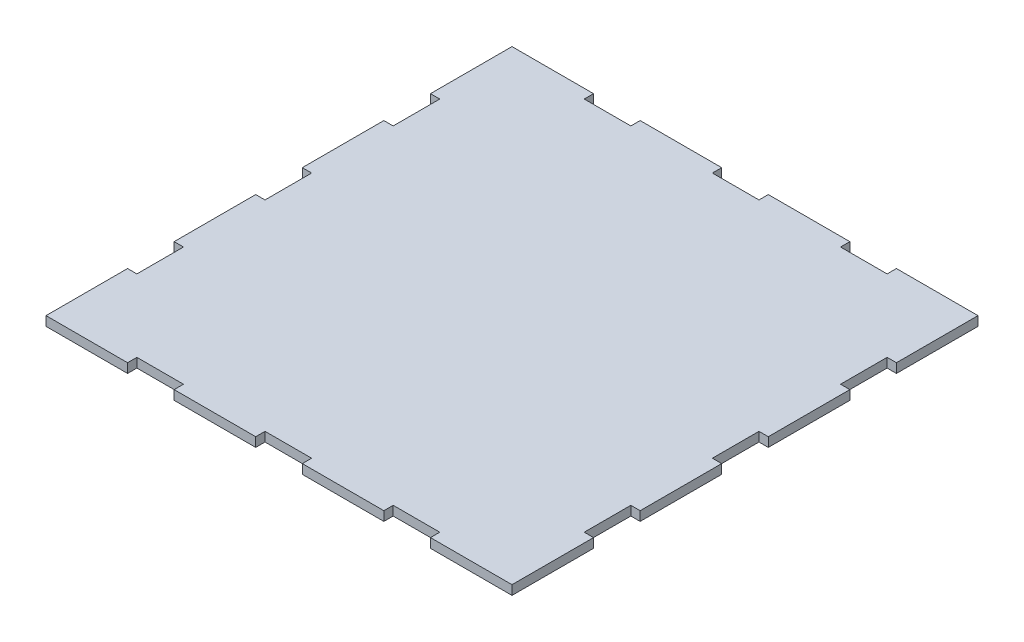
from build123d import *

# Parameters (mm, degrees)
ESBO_O1_W                = 200
ESBO_O1_H                = 200
RESSALTO_EXTRUS_O1_DEPTH = 4
ESBO_O2_W                = 20
ESBO_O2_H                = 4
ESBO_O2_W_2              = 4
ESBO_O2_H_2              = 20
CORTE_EXTRUS_O1_DEPTH    = 5


with BuildPart() as part:
    # Esboço1 → Ressalto-extrusão1 (new body)
    with BuildSketch(Plane(origin=(0, 0, 0), x_dir=(1, 0, 0), z_dir=(0, 1, 0))):
        Rectangle(ESBO_O1_W, ESBO_O1_H)
    extrude(amount=RESSALTO_EXTRUS_O1_DEPTH)

    # Esboço2 → Corte-extrusão1 (cut, through all)
    with BuildSketch(Plane(origin=(0, 4, 0), x_dir=(1, 0, 0), z_dir=(0, 1, 0))):
        with Locations((-55, 98)):
            Rectangle(ESBO_O2_W, ESBO_O2_H)
        with Locations((55, 98)):
            Rectangle(ESBO_O2_W, ESBO_O2_H)
        with Locations((0, 98)):
            Rectangle(ESBO_O2_W, ESBO_O2_H)
        with Locations((98, 55)):
            Rectangle(ESBO_O2_W_2, ESBO_O2_H_2)
        with Locations((98, 0)):
            Rectangle(ESBO_O2_W_2, ESBO_O2_H_2)
        with Locations((98, -55)):
            Rectangle(ESBO_O2_W_2, ESBO_O2_H_2)
        with Locations((-98, 0)):
            Rectangle(ESBO_O2_W_2, ESBO_O2_H_2)
        with Locations((-98, -55)):
            Rectangle(ESBO_O2_W_2, ESBO_O2_H_2)
        with Locations((-98, 55)):
            Rectangle(ESBO_O2_W_2, ESBO_O2_H_2)
        with Locations((55, -98)):
            Rectangle(ESBO_O2_W, ESBO_O2_H)
        with Locations((-55, -98)):
            Rectangle(ESBO_O2_W, ESBO_O2_H)
        with Locations((0, -98)):
            Rectangle(ESBO_O2_W, ESBO_O2_H)
    extrude(amount=-CORTE_EXTRUS_O1_DEPTH, mode=Mode.SUBTRACT)


solid = part.part
